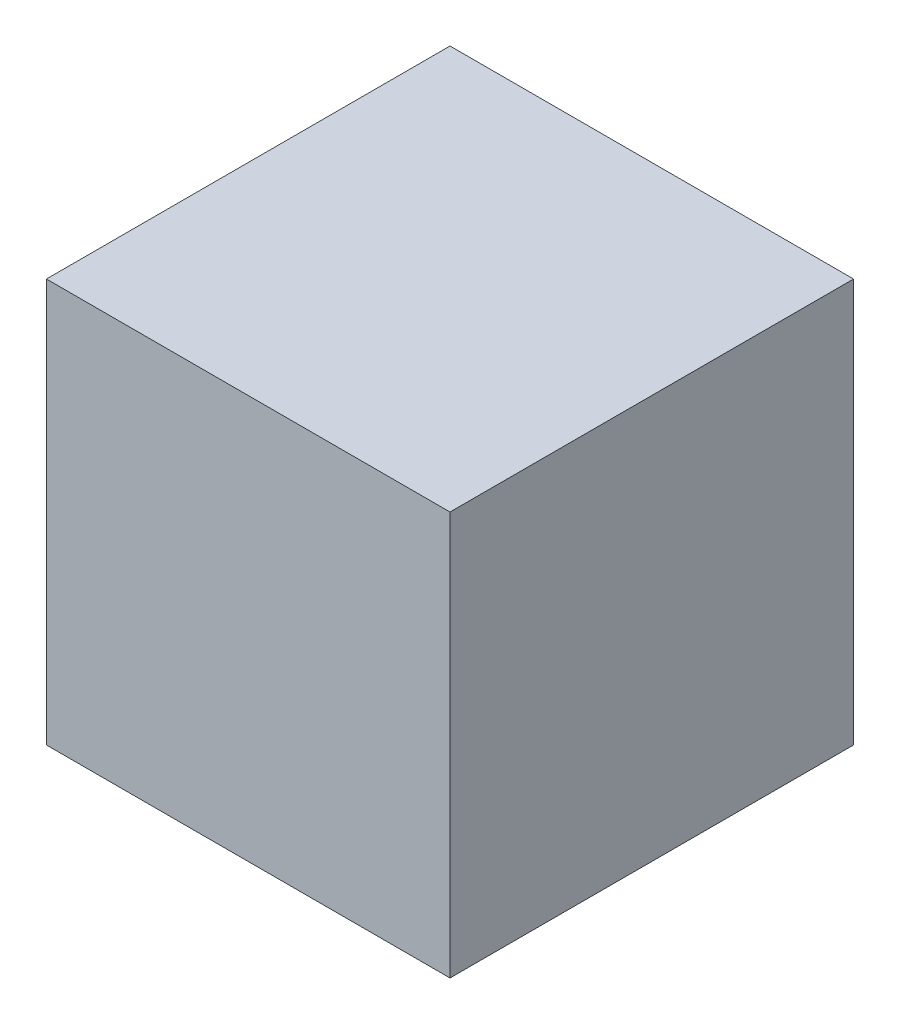
from build123d import *

# Parameters (mm, degrees)
SKIZZE1_W               = 100
SKIZZE1_H               = 100
LINEAR_AUSTRAGEN1_DEPTH = 50


with BuildPart() as part:
    # Skizze1 → Linear austragen1 (new body, symmetric)
    with BuildSketch(Plane(origin=(0, 0, 0), x_dir=(1, 0, 0), z_dir=(0, 1, 0))):
        with Locations((50, 50)):
            Rectangle(SKIZZE1_W, SKIZZE1_H)
    extrude(amount=LINEAR_AUSTRAGEN1_DEPTH, both=True)


solid = part.part
